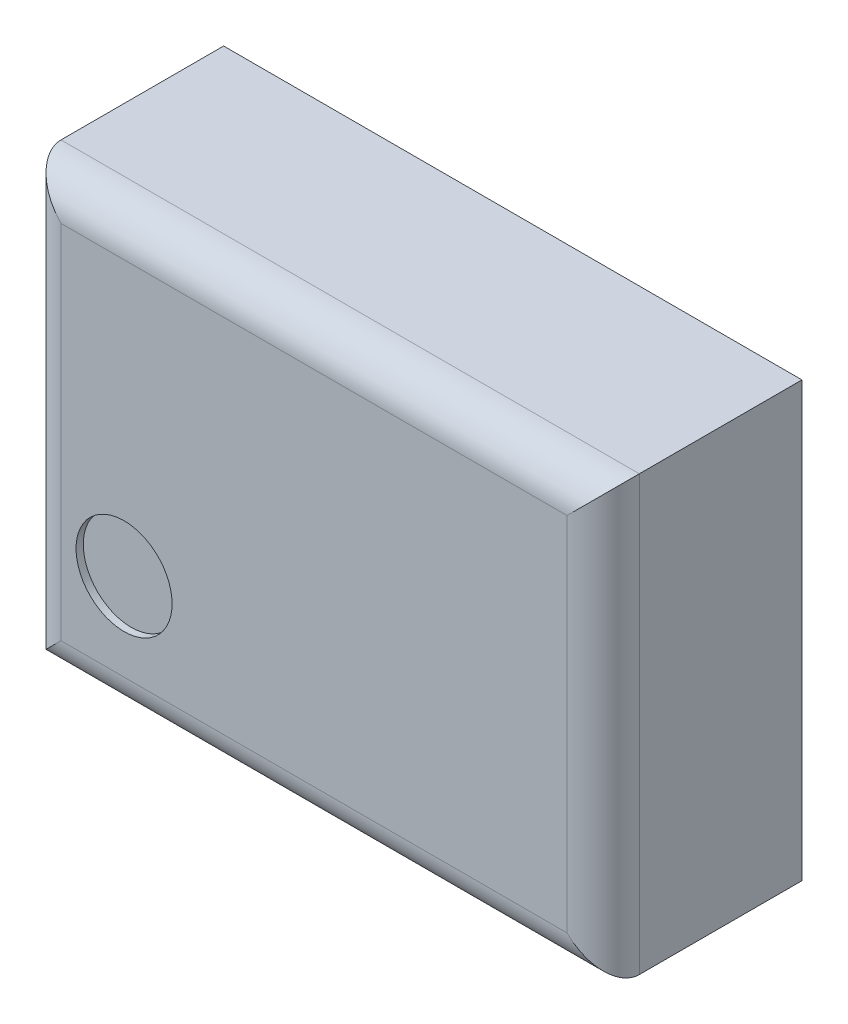
from build123d import *

# Parameters (mm, degrees)
BOSS_EXTRUDE1_START = 0.05
SKETCH1_W           = 1.6
SKETCH1_H           = 1.2
BOSS_EXTRUDE1_DEPTH = 0.55
BOSS_EXTRUDE2_REACH = 2.6
SKETCH2_W           = 0.5
SKETCH2_H           = 0.4
FILLET1_R           = 0.1
SKETCH3_R           = 0.132827507
CUT_EXTRUDE1_DEPTH  = 0.02


with BuildPart() as part:
    # Sketch1 → Boss-Extrude1 (new body)
    with BuildSketch(Plane.XY.offset(BOSS_EXTRUDE1_START)):
        Rectangle(SKETCH1_W, SKETCH1_H)
    extrude(amount=BOSS_EXTRUDE1_DEPTH)

    # Sketch2 → Boss-Extrude2 (add, up to next)
    with BuildSketch(Plane.XY, mode=Mode.PRIVATE) as boss_extrude2_sk1:
        with Locations((-0.5, 0.35)):
            Rectangle(SKETCH2_W, SKETCH2_H)
    boss_extrude2_tool1 = extrude(boss_extrude2_sk1.sketch, amount=BOSS_EXTRUDE2_REACH, mode=Mode.PRIVATE) - part.part
    add(boss_extrude2_tool1.solids().sort_by_distance((-0.5, 0.35, 0))[0])
    # Sketch2 → Boss-Extrude2 (add, up to next)
    with BuildSketch(Plane.XY, mode=Mode.PRIVATE) as boss_extrude2_sk2:
        with Locations((-0.5, -0.35)):
            Rectangle(SKETCH2_W, SKETCH2_H)
    boss_extrude2_tool2 = extrude(boss_extrude2_sk2.sketch, amount=BOSS_EXTRUDE2_REACH, mode=Mode.PRIVATE) - part.part
    add(boss_extrude2_tool2.solids().sort_by_distance((-0.5, -0.35, 0))[0])
    # Sketch2 → Boss-Extrude2 (add, up to next)
    with BuildSketch(Plane.XY, mode=Mode.PRIVATE) as boss_extrude2_sk3:
        with Locations((0.5, 0.35)):
            Rectangle(SKETCH2_W, SKETCH2_H)
    boss_extrude2_tool3 = extrude(boss_extrude2_sk3.sketch, amount=BOSS_EXTRUDE2_REACH, mode=Mode.PRIVATE) - part.part
    add(boss_extrude2_tool3.solids().sort_by_distance((0.5, 0.35, 0))[0])
    # Sketch2 → Boss-Extrude2 (add, up to next)
    with BuildSketch(Plane.XY, mode=Mode.PRIVATE) as boss_extrude2_sk4:
        with Locations((0.5, -0.35)):
            Rectangle(SKETCH2_W, SKETCH2_H)
    boss_extrude2_tool4 = extrude(boss_extrude2_sk4.sketch, amount=BOSS_EXTRUDE2_REACH, mode=Mode.PRIVATE) - part.part
    add(boss_extrude2_tool4.solids().sort_by_distance((0.5, -0.35, 0))[0])

    # Fillet1
    fillet1_edges = [part.edges().sort_by_distance(p)[0] for p in [
        (-0.8, 0, 0.6),
        (0, -0.6, 0.6),
        (0.8, 0, 0.6),
        (0, 0.6, 0.6),
    ]]
    fillet(fillet1_edges, radius=FILLET1_R)

    # Sketch3 → Cut-Extrude1 (cut)
    with BuildSketch(Plane.XY.offset(0.6)):
        with Locations((-0.525466391, -0.258003209)):
            Circle(SKETCH3_R)
    extrude(amount=-CUT_EXTRUDE1_DEPTH, mode=Mode.SUBTRACT)


solid = part.part
